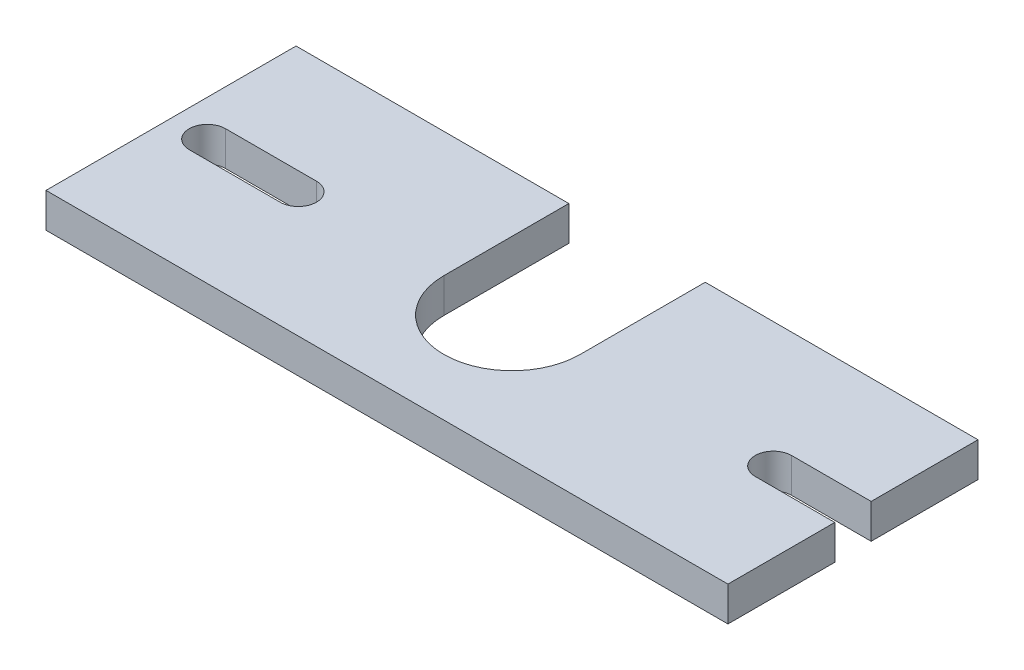
from build123d import *

# Parameters (mm, degrees)
BOSS_EXTRUDE1_DEPTH = 3.04


with BuildPart() as part:
    # Sketch1 → Boss-Extrude1 (new body)
    with BuildSketch(Plane(origin=(0, 0, 0), x_dir=(1, 0, 0), z_dir=(0, 1, 0))):
        with BuildLine():
            Line((0, 0), (60, 0))
            Line((60, 0), (60, 9.4))
            Line((60, 9.4), (53, 9.4))
            ThreePointArc((53, 9.4), (51.4, 11), (53, 12.6))
            Line((53, 12.6), (60, 12.6))
            Line((60, 12.6), (60, 22))
            Line((60, 22), (36, 22))
            Line((36, 22), (36, 11))
            ThreePointArc((36, 11), (30, 5), (24, 11))
            Line((24, 11), (24, 22))
            Line((24, 22), (0, 22))
            Line((0, 22), (0, 0))
        make_face()
        with BuildLine():
            Line((3.2, 12.6), (11.2, 12.6))
            ThreePointArc((11.2, 12.6), (12.8, 11), (11.2, 9.4))
            Line((11.2, 9.4), (3.2, 9.4))
            ThreePointArc((3.2, 9.4), (1.6, 11), (3.2, 12.6))
        make_face(mode=Mode.SUBTRACT)
    extrude(amount=BOSS_EXTRUDE1_DEPTH)


solid = part.part
